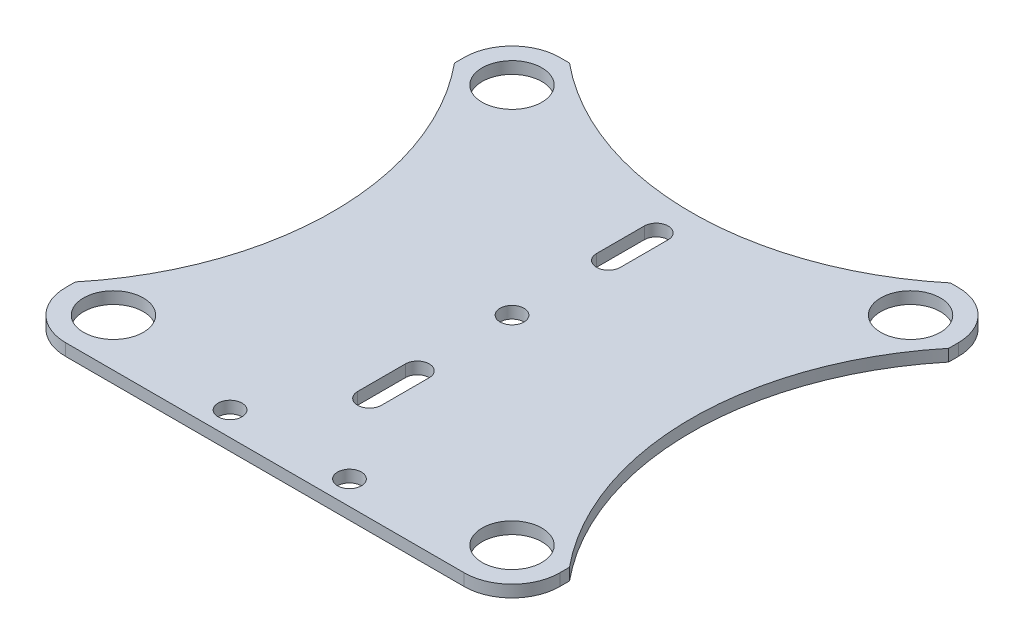
from build123d import *

# Parameters (mm, degrees)
SKETCH1_R           = 5
SKETCH1_R_2         = 2
BOSS_EXTRUDE1_DEPTH = 2


with BuildPart() as part:
    # Sketch1 → Boss-Extrude1 (new body)
    with BuildSketch(Plane(origin=(0, 0, 0), x_dir=(1, 0, 0), z_dir=(0, 1, 0))):
        with BuildLine():
            Line((32.038903515, 41.368938053), (33.368938053, 41.368938053))
            ThreePointArc((33.368938053, 41.368938053), (39.025792302, 39.025792302), (41.368938053, 33.368938053))
            Line((41.368938053, 33.368938053), (41.368938053, 31.743362343))
            ThreePointArc((41.368938053, 31.743362343), (30, 0), (41.368938053, -31.743362343))
            Line((41.368938053, -31.743362343), (41.368938053, -33.368938053))
            ThreePointArc((41.368938053, -33.368938053), (39.025792302, -39.025792302), (33.368938053, -41.368938053))
            Line((33.368938053, -41.368938053), (32.038903515, -41.368938053))
            Line((32.038903515, -41.368938053), (-31.743362343, -41.368938053))
            Line((-31.743362343, -41.368938053), (-33.368938053, -41.368938053))
            ThreePointArc((-33.368938053, -41.368938053), (-39.025792302, -39.025792302), (-41.368938053, -33.368938053))
            Line((-41.368938053, -33.368938053), (-41.368938053, -31.743362343))
            ThreePointArc((-41.368938053, -31.743362343), (-30, 0), (-41.368938053, 31.743362343))
            Line((-41.368938053, 31.743362343), (-41.368938053, 33.368938053))
            ThreePointArc((-41.368938053, 33.368938053), (-39.025792302, 39.025792302), (-33.368938053, 41.368938053))
            Line((-33.368938053, 41.368938053), (-31.743362343, 41.368938053))
            ThreePointArc((-31.743362343, 41.368938053), (0.147770586, 29.90602396), (32.038903515, 41.368938053))
        make_face()
        with Locations((-33.368938053, 33.368938053)):
            Circle(SKETCH1_R, mode=Mode.SUBTRACT)
        with Locations((33.368938053, 33.368938053)):
            Circle(SKETCH1_R, mode=Mode.SUBTRACT)
        with Locations((-33.368938053, -33.368938053)):
            Circle(SKETCH1_R, mode=Mode.SUBTRACT)
        with Locations((33.368938053, -33.368938053)):
            Circle(SKETCH1_R, mode=Mode.SUBTRACT)
        Circle(SKETCH1_R_2, mode=Mode.SUBTRACT)
        with Locations((10.147770586, -37.36127525)):
            Circle(SKETCH1_R_2, mode=Mode.SUBTRACT)
        with Locations((-9.852229414, -37.36127525)):
            Circle(SKETCH1_R_2, mode=Mode.SUBTRACT)
        with BuildLine():
            Line((2.147770586, 24), (2.147770586, 16))
            ThreePointArc((2.147770586, 16), (0.147770586, 14), (-1.852229414, 16))
            Line((-1.852229414, 16), (-1.852229414, 24))
            ThreePointArc((-1.852229414, 24), (0.147770586, 26), (2.147770586, 24))
        make_face(mode=Mode.SUBTRACT)
        with BuildLine():
            Line((-1.852229414, -24), (-1.852229414, -16))
            ThreePointArc((-1.852229414, -16), (0.147770586, -14), (2.147770586, -16))
            Line((2.147770586, -16), (2.147770586, -24))
            ThreePointArc((2.147770586, -24), (0.147770586, -26), (-1.852229414, -24))
        make_face(mode=Mode.SUBTRACT)
    extrude(amount=BOSS_EXTRUDE1_DEPTH)


solid = part.part
